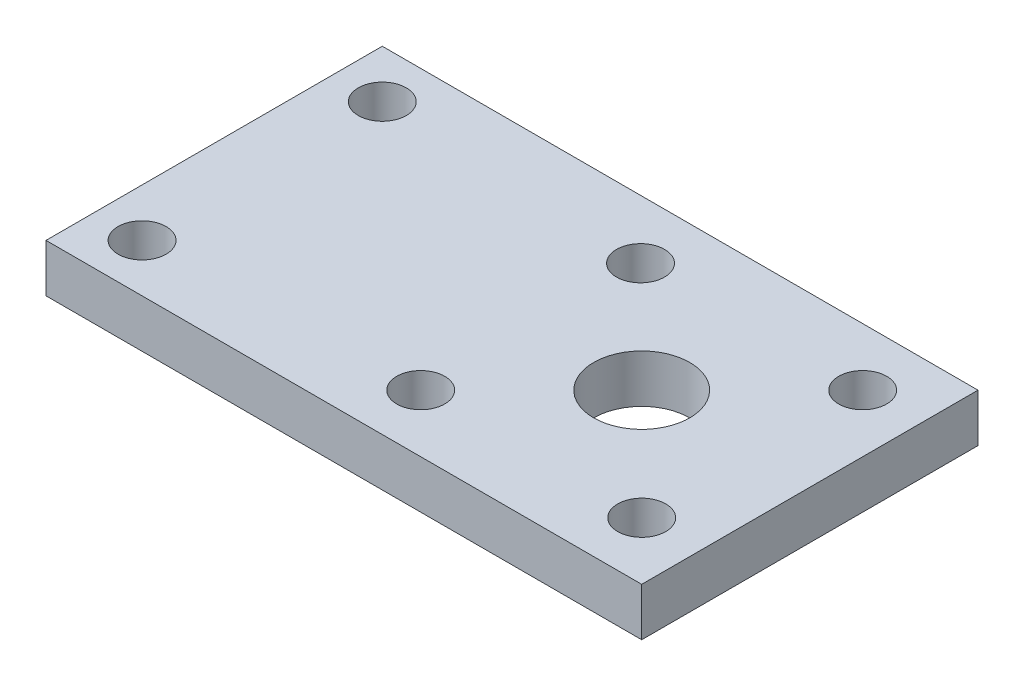
from build123d import *

# Parameters (mm, degrees)
SKETCH1_W           = 62
SKETCH1_H           = 35
BOSS_EXTRUDE1_DEPTH = 5
SKETCH2_R           = 2.5
CUT_EXTRUDE1_DEPTH  = 6
SKETCH3_R           = 2.5
SKETCH3_R_2         = 5
CUT_EXTRUDE2_DEPTH  = 6


with BuildPart() as part:
    # Sketch1 → Boss-Extrude1 (new body)
    with BuildSketch(Plane(origin=(0, 0, 0), x_dir=(1, 0, 0), z_dir=(0, 1, 0))):
        with Locations((31, 17.5)):
            Rectangle(SKETCH1_W, SKETCH1_H)
    extrude(amount=BOSS_EXTRUDE1_DEPTH)

    # Sketch2 → Cut-Extrude1 (cut, through all)
    with BuildSketch(Plane(origin=(0, 5, 0), x_dir=(1, 0, 0), z_dir=(0, 1, 0))):
        with Locations((5, 30)):
            Circle(SKETCH2_R)
        with Locations((5, 5)):
            Circle(SKETCH2_R)
    extrude(amount=-CUT_EXTRUDE1_DEPTH, mode=Mode.SUBTRACT)

    # Sketch3 → Cut-Extrude2 (cut, through all)
    with BuildSketch(Plane(origin=(0, 5, 0), x_dir=(1, 0, 0), z_dir=(0, 1, 0))):
        with Locations((56, 29)):
            Circle(SKETCH3_R)
        with Locations((56, 6)):
            Circle(SKETCH3_R)
        with Locations((33, 28.877597721)):
            Circle(SKETCH3_R)
        with Locations((33, 6)):
            Circle(SKETCH3_R)
        with Locations((44.5, 17.5)):
            Circle(SKETCH3_R_2)
    extrude(amount=-CUT_EXTRUDE2_DEPTH, mode=Mode.SUBTRACT)


solid = part.part
